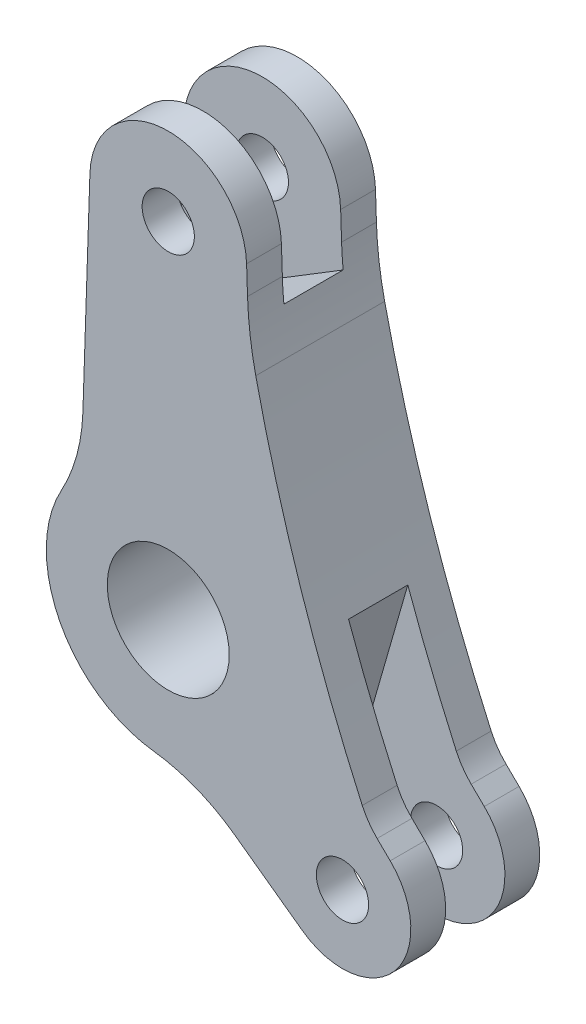
from build123d import *

# Parameters (mm, degrees)
SKETCH1_R           = 1.75
SKETCH1_R_2         = 0.75
BOSS_EXTRUDE1_DEPTH = 1.85
CUT_EXTRUDE1_DEPTH  = 0.85


with BuildPart() as part:
    # Sketch1 → Boss-Extrude1 (new body, symmetric)
    with BuildSketch(Plane.XY):
        with BuildLine():
            Line((-2.248747058, 9.975077763), (-2.450586667, 3.929529668))
            ThreePointArc((-2.450586667, 3.929529668), (-2.626439392, 2.771809131), (-3.066742144, 1.686740235))
            ThreePointArc((-3.066742144, 1.686740235), (-3.115718571, -1.594458461), (-0.425746012, -3.474009259))
            ThreePointArc((-0.425746012, -3.474009259), (0.794490836, -3.783194285), (1.898835448, -4.387343542))
            Line((1.898835448, -4.387343542), (3.849546842, -5.800104619))
            ThreePointArc((3.849546842, -5.800104619), (6.502194953, -5.474619694), (6.371070446, -2.805296035))
            Line((6.371070446, -2.805296035), (5.994743374, -2.438319573))
            ThreePointArc((5.994743374, -2.438319573), (5.753103265, -2.154083372), (5.568455785, -1.829914483))
            ThreePointArc((5.568455785, -1.829914483), (3.806333847, 2.668506691), (2.511577358, 7.323017665))
            ThreePointArc((2.511577358, 7.323017665), (2.35023388, 8.243248269), (2.275474866, 9.174520072))
            Line((2.275474866, 9.174520072), (2.248747058, 9.975077763))
            ThreePointArc((2.248747058, 9.975077763), (0, 12.15), (-2.248747058, 9.975077763))
        make_face()
        Circle(SKETCH1_R, mode=Mode.SUBTRACT)
        with Locations((0, 9.9)):
            Circle(SKETCH1_R_2, mode=Mode.SUBTRACT)
        with Locations((5.000791037, -4.210490349)):
            Circle(SKETCH1_R_2, mode=Mode.SUBTRACT)
    extrude(amount=BOSS_EXTRUDE1_DEPTH, both=True)

    # Sketch2 → Cut-Extrude1 (cut, symmetric)
    with BuildSketch(Plane.XY):
        Polygon((1.704938045, -6.98647295), (4.176020114, 1.603907731), (8.214802736, -2.706528486), (6.17955487, -9.771778434), align=None)
        Polygon((-2.39415597, 5.619755358), (2.320198625, 8.506541147), (8.539776122, 16.638706119), (-7.891989788, 11.77086667), align=None)
    extrude(amount=CUT_EXTRUDE1_DEPTH, both=True, mode=Mode.SUBTRACT)


solid = part.part
